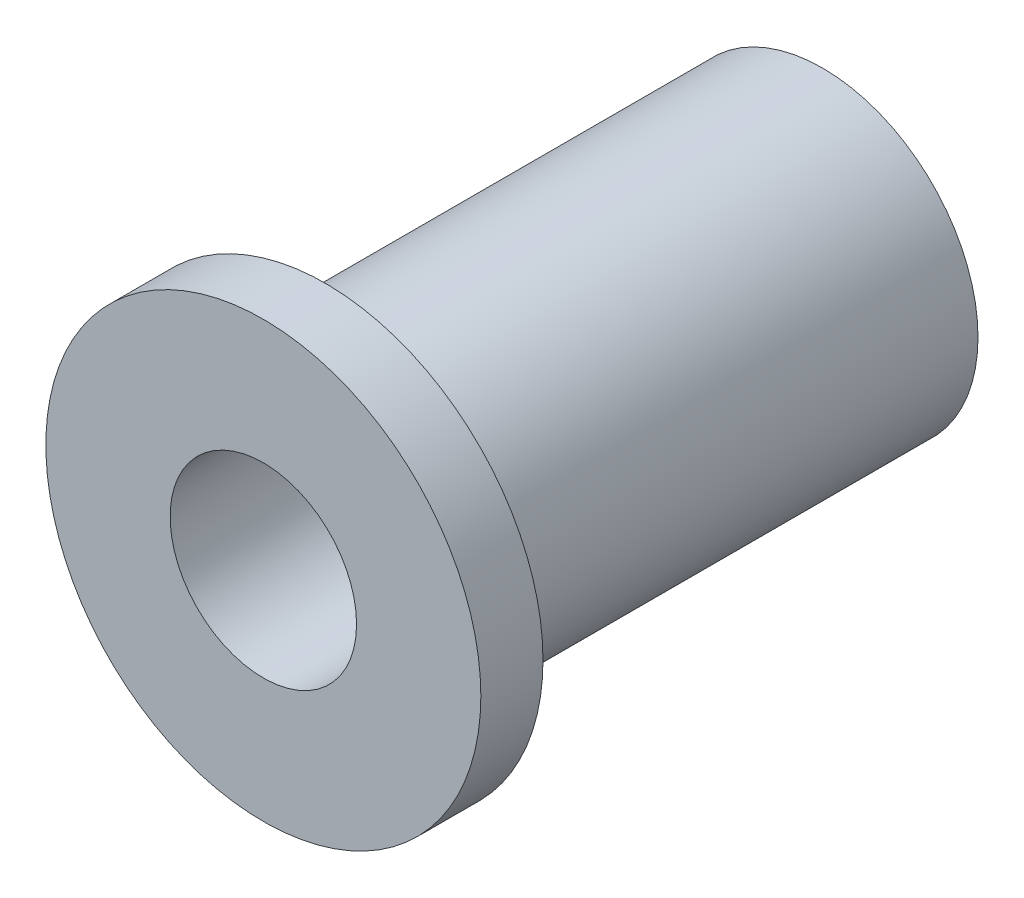
from build123d import *

# Parameters (mm, degrees)
SKETCH1_R           = 5.55625
BOSS_EXTRUDE1_DEPTH = 1.5875
SKETCH2_R           = 3.96875
BOSS_EXTRUDE2_DEPTH = 12.7
SKETCH3_R           = 2.38125
CUT_EXTRUDE1_DEPTH  = 15.2875


with BuildPart() as part:
    # Sketch1 → Boss-Extrude1 (new body)
    with BuildSketch(Plane.XY):
        Circle(SKETCH1_R)
    extrude(amount=BOSS_EXTRUDE1_DEPTH)

    # Sketch2 → Boss-Extrude2 (add)
    with BuildSketch(Plane(origin=(0, 0, 0), x_dir=(-1, 0, 0), z_dir=(0, 0, -1))):
        Circle(SKETCH2_R)
    extrude(amount=BOSS_EXTRUDE2_DEPTH)

    # Sketch3 → Cut-Extrude1 (cut, through all)
    with BuildSketch(Plane.XY.offset(1.5875)):
        Circle(SKETCH3_R)
    extrude(amount=-CUT_EXTRUDE1_DEPTH, mode=Mode.SUBTRACT)


solid = part.part
